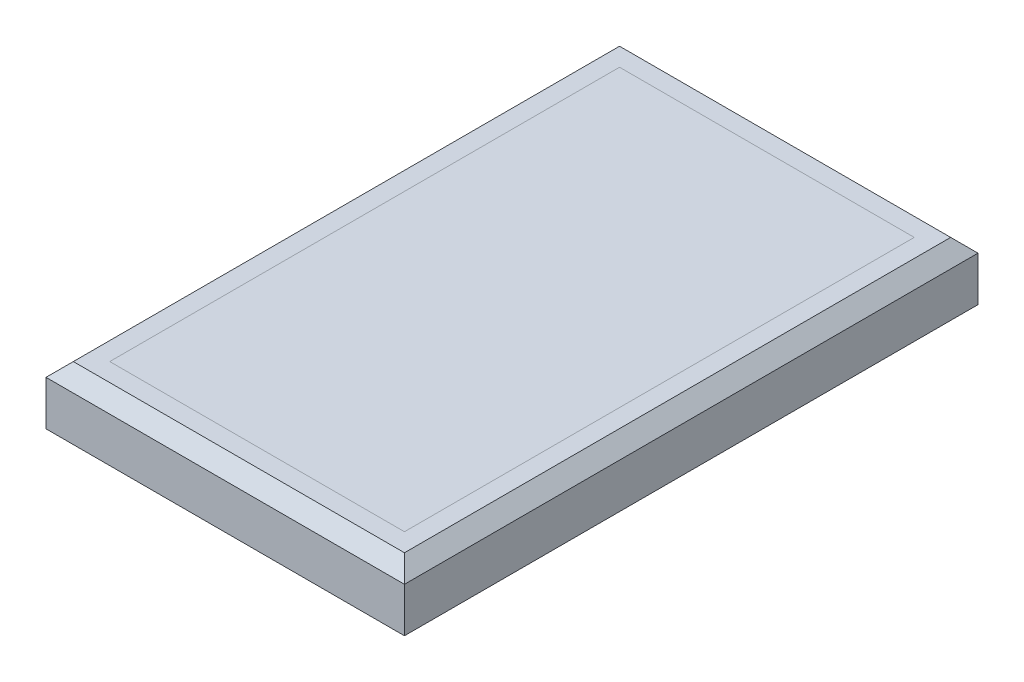
from build123d import *

# Parameters (mm, degrees)
SKETCH1_W           = 250.000000126
SKETCH1_H           = 400.0000001
BOSS_EXTRUDE1_DEPTH = 40.64
SKETCH2_W           = 205.550000126
SKETCH2_H           = 355.5500001
CUT_EXTRUDE1_DEPTH  = 38.1
CHAMFER1_SIZE       = 9.525
SKETCH3_W           = 205.550000126
SKETCH3_H           = 355.5500001
BOSS_EXTRUDE2_DEPTH = 3.175
SKETCH4_W           = 3.175
SKETCH4_H           = 355.5500001
CUT_EXTRUDE2_DEPTH  = 7.62
SKETCH5_W           = 205.550000126
SKETCH5_H           = 3.175
CUT_EXTRUDE3_DEPTH  = 7.62
SKETCH6_W           = 31.612500021
SKETCH6_H           = 32.69750001
BOSS_EXTRUDE3_DEPTH = 3.175
SKETCH7_W           = 199.200000126
SKETCH7_H           = 349.2000001
CUT_EXTRUDE4_DEPTH  = 7.62
SKETCH9_W           = 205.550000126
SKETCH9_H           = 355.5500001
BOSS_EXTRUDE5_DEPTH = 3.175
SKETCH10_W          = 199.200000126
SKETCH10_H          = 349.2000001
BOSS_EXTRUDE6_DEPTH = 3.175


with BuildPart() as part:
    # Sketch1 → Boss-Extrude1 (new body)
    with BuildSketch(Plane(origin=(0, 0, 0), x_dir=(1, 0, 0), z_dir=(0, 1, 0))):
        Rectangle(SKETCH1_W, SKETCH1_H)
    extrude(amount=BOSS_EXTRUDE1_DEPTH)

    # Sketch2 → Cut-Extrude1 (cut)
    with BuildSketch(Plane(origin=(0, 40.64, 0), x_dir=(1, 0, 0), z_dir=(0, 1, 0))):
        Rectangle(SKETCH2_W, SKETCH2_H)
    extrude(amount=-CUT_EXTRUDE1_DEPTH, mode=Mode.SUBTRACT)

    # Chamfer1
    chamfer1_edges = [part.edges().sort_by_distance(p)[0] for p in [
        (125.000000063, 40.64, 0),
        (0, 40.64, -200.00000005),
        (-125.000000063, 40.64, 0),
        (0, 40.64, 200.00000005),
    ]]
    chamfer(chamfer1_edges, length=CHAMFER1_SIZE)

    # Sketch7 → Cut-Extrude4 (cut)
    with BuildSketch(Plane.XZ):
        Rectangle(SKETCH7_W, SKETCH7_H)
    extrude(amount=-CUT_EXTRUDE4_DEPTH, mode=Mode.SUBTRACT)


with BuildPart() as body_2:
    # Sketch3 → Boss-Extrude2 (new body)
    with BuildSketch(Plane(origin=(0, 37.465, 0), x_dir=(1, 0, 0), z_dir=(0, 1, 0))):
        Rectangle(SKETCH3_W, SKETCH3_H)
    extrude(amount=-BOSS_EXTRUDE2_DEPTH)

    # Sketch4 → Cut-Extrude2 (cut)
    with BuildSketch(Plane(origin=(0, 37.465, 0), x_dir=(1, 0, 0), z_dir=(0, 1, 0))):
        Rectangle(SKETCH4_W, SKETCH4_H)
        with Locations((69.575000042, 0)):
            Rectangle(SKETCH4_W, SKETCH4_H)
        with Locations((-69.575000042, 0)):
            Rectangle(SKETCH4_W, SKETCH4_H)
        with Locations((34.787500021, 0)):
            Rectangle(SKETCH4_W, SKETCH4_H)
        with Locations((-34.787500021, 0)):
            Rectangle(SKETCH4_W, SKETCH4_H)
    extrude(amount=-CUT_EXTRUDE2_DEPTH, mode=Mode.SUBTRACT)

    # Sketch5 → Cut-Extrude3 (cut)
    with BuildSketch(Plane(origin=(0, 37.465, 0), x_dir=(1, 0, 0), z_dir=(0, 1, 0))):
        Rectangle(SKETCH5_W, SKETCH5_H)
        with Locations((0, -35.87250001)):
            Rectangle(SKETCH5_W, SKETCH5_H)
        with Locations((0, -71.74500002)):
            Rectangle(SKETCH5_W, SKETCH5_H)
        with Locations((0, -107.61750003)):
            Rectangle(SKETCH5_W, SKETCH5_H)
        with Locations((0, -143.49000004)):
            Rectangle(SKETCH5_W, SKETCH5_H)
        with Locations((0, 35.87250001)):
            Rectangle(SKETCH5_W, SKETCH5_H)
        with Locations((0, 71.74500002)):
            Rectangle(SKETCH5_W, SKETCH5_H)
        with Locations((0, 107.61750003)):
            Rectangle(SKETCH5_W, SKETCH5_H)
        with Locations((0, 143.49000004)):
            Rectangle(SKETCH5_W, SKETCH5_H)
    extrude(amount=-CUT_EXTRUDE3_DEPTH, mode=Mode.SUBTRACT)


with BuildPart() as body_3:
    # Sketch6 → Boss-Extrude3 (new body)
    with BuildSketch(Plane(origin=(0, 37.465, 0), x_dir=(1, 0, 0), z_dir=(0, 1, 0))):
        Polygon((-102.775000063, -141.90250004), (-102.775000063, -145.07750004), (-71.162500042, -145.07750004), (-71.162500042, -177.77500005), (-67.987500042, -177.77500005), (-67.987500042, -145.07750004), (-36.375000021, -145.07750004), (-36.375000021, -177.77500005), (-33.200000021, -177.77500005), (-33.200000021, -145.07750004), (-1.5875, -145.07750004), (-1.5875, -177.77500005), (1.5875, -177.77500005), (1.5875, -145.07750004), (33.200000021, -145.07750004), (33.200000021, -177.77500005), (36.375000021, -177.77500005), (36.375000021, -145.07750004), (67.987500042, -145.07750004), (67.987500042, -177.77500005), (71.162500042, -177.77500005), (71.162500042, -145.07750004), (102.775000063, -145.07750004), (102.775000063, -141.90250004), (71.162500042, -141.90250004), (71.162500042, -109.20500003), (102.775000063, -109.20500003), (102.775000063, -106.03000003), (71.162500042, -106.03000003), (71.162500042, -73.33250002), (102.775000063, -73.33250002), (102.775000063, -70.15750002), (71.162500042, -70.15750002), (71.162500042, -37.46000001), (102.775000063, -37.46000001), (102.775000063, -34.28500001), (71.162500042, -34.28500001), (71.162500042, -1.5875), (102.775000063, -1.5875), (102.775000063, 1.5875), (71.162500042, 1.5875), (71.162500042, 34.28500001), (102.775000063, 34.28500001), (102.775000063, 37.46000001), (71.162500042, 37.46000001), (71.162500042, 70.15750002), (102.775000063, 70.15750002), (102.775000063, 73.33250002), (71.162500042, 73.33250002), (71.162500042, 106.03000003), (102.775000063, 106.03000003), (102.775000063, 109.20500003), (71.162500042, 109.20500003), (71.162500042, 141.90250004), (102.775000063, 141.90250004), (102.775000063, 145.07750004), (71.162500042, 145.07750004), (71.162500042, 177.77500005), (67.987500042, 177.77500005), (67.987500042, 145.07750004), (36.375000021, 145.07750004), (36.375000021, 177.77500005), (33.200000021, 177.77500005), (33.200000021, 145.07750004), (1.5875, 145.07750004), (1.5875, 177.77500005), (-1.5875, 177.77500005), (-1.5875, 145.07750004), (-33.200000021, 145.07750004), (-33.200000021, 177.77500005), (-36.375000021, 177.77500005), (-36.375000021, 145.07750004), (-67.987500042, 145.07750004), (-67.987500042, 177.77500005), (-71.162500042, 177.77500005), (-71.162500042, 145.07750004), (-102.775000063, 145.07750004), (-102.775000063, 141.90250004), (-71.162500042, 141.90250004), (-71.162500042, 109.20500003), (-102.775000063, 109.20500003), (-102.775000063, 106.03000003), (-71.162500042, 106.03000003), (-71.162500042, 73.33250002), (-102.775000063, 73.33250002), (-102.775000063, 70.15750002), (-71.162500042, 70.15750002), (-71.162500042, 37.46000001), (-102.775000063, 37.46000001), (-102.775000063, 34.28500001), (-71.162500042, 34.28500001), (-71.162500042, 1.5875), (-102.775000063, 1.5875), (-102.775000063, -1.5875), (-71.162500042, -1.5875), (-71.162500042, -34.28500001), (-102.775000063, -34.28500001), (-102.775000063, -37.46000001), (-71.162500042, -37.46000001), (-71.162500042, -70.15750002), (-102.775000063, -70.15750002), (-102.775000063, -73.33250002), (-71.162500042, -73.33250002), (-71.162500042, -106.03000003), (-102.775000063, -106.03000003), (-102.775000063, -109.20500003), (-71.162500042, -109.20500003), (-71.162500042, -141.90250004), align=None)
        with Locations((-52.181250032, -125.553750035)):
            Rectangle(SKETCH6_W, SKETCH6_H, mode=Mode.SUBTRACT)
        with Locations((-17.39375001, -125.553750035)):
            Rectangle(SKETCH6_W, SKETCH6_H, mode=Mode.SUBTRACT)
        with Locations((17.39375001, -125.553750035)):
            Rectangle(SKETCH6_W, SKETCH6_H, mode=Mode.SUBTRACT)
        with Locations((52.181250032, -125.553750035)):
            Rectangle(SKETCH6_W, SKETCH6_H, mode=Mode.SUBTRACT)
        with Locations((52.181250032, -89.681250025)):
            Rectangle(SKETCH6_W, SKETCH6_H, mode=Mode.SUBTRACT)
        with Locations((17.39375001, -89.681250025)):
            Rectangle(SKETCH6_W, SKETCH6_H, mode=Mode.SUBTRACT)
        with Locations((-17.39375001, -89.681250025)):
            Rectangle(SKETCH6_W, SKETCH6_H, mode=Mode.SUBTRACT)
        with Locations((-52.181250032, -89.681250025)):
            Rectangle(SKETCH6_W, SKETCH6_H, mode=Mode.SUBTRACT)
        with Locations((-52.181250032, -53.808750015)):
            Rectangle(SKETCH6_W, SKETCH6_H, mode=Mode.SUBTRACT)
        with Locations((-17.39375001, -53.808750015)):
            Rectangle(SKETCH6_W, SKETCH6_H, mode=Mode.SUBTRACT)
        with Locations((17.39375001, -53.808750015)):
            Rectangle(SKETCH6_W, SKETCH6_H, mode=Mode.SUBTRACT)
        with Locations((52.181250032, -53.808750015)):
            Rectangle(SKETCH6_W, SKETCH6_H, mode=Mode.SUBTRACT)
        with Locations((52.181250032, -17.936250005)):
            Rectangle(SKETCH6_W, SKETCH6_H, mode=Mode.SUBTRACT)
        with Locations((17.39375001, -17.936250005)):
            Rectangle(SKETCH6_W, SKETCH6_H, mode=Mode.SUBTRACT)
        with Locations((-17.39375001, -17.936250005)):
            Rectangle(SKETCH6_W, SKETCH6_H, mode=Mode.SUBTRACT)
        with Locations((-52.181250032, -17.936250005)):
            Rectangle(SKETCH6_W, SKETCH6_H, mode=Mode.SUBTRACT)
        with Locations((-52.181250032, 17.936250005)):
            Rectangle(SKETCH6_W, SKETCH6_H, mode=Mode.SUBTRACT)
        with Locations((-17.39375001, 17.936250005)):
            Rectangle(SKETCH6_W, SKETCH6_H, mode=Mode.SUBTRACT)
        with Locations((17.39375001, 17.936250005)):
            Rectangle(SKETCH6_W, SKETCH6_H, mode=Mode.SUBTRACT)
        with Locations((52.181250032, 17.936250005)):
            Rectangle(SKETCH6_W, SKETCH6_H, mode=Mode.SUBTRACT)
        with Locations((52.181250032, 125.553750035)):
            Rectangle(SKETCH6_W, SKETCH6_H, mode=Mode.SUBTRACT)
        with Locations((52.181250032, 89.681250025)):
            Rectangle(SKETCH6_W, SKETCH6_H, mode=Mode.SUBTRACT)
        with Locations((52.181250032, 53.808750015)):
            Rectangle(SKETCH6_W, SKETCH6_H, mode=Mode.SUBTRACT)
        with Locations((17.39375001, 53.808750015)):
            Rectangle(SKETCH6_W, SKETCH6_H, mode=Mode.SUBTRACT)
        with Locations((17.39375001, 89.681250025)):
            Rectangle(SKETCH6_W, SKETCH6_H, mode=Mode.SUBTRACT)
        with Locations((17.39375001, 125.553750035)):
            Rectangle(SKETCH6_W, SKETCH6_H, mode=Mode.SUBTRACT)
        with Locations((-17.39375001, 125.553750035)):
            Rectangle(SKETCH6_W, SKETCH6_H, mode=Mode.SUBTRACT)
        with Locations((-17.39375001, 89.681250025)):
            Rectangle(SKETCH6_W, SKETCH6_H, mode=Mode.SUBTRACT)
        with Locations((-17.39375001, 53.808750015)):
            Rectangle(SKETCH6_W, SKETCH6_H, mode=Mode.SUBTRACT)
        with Locations((-52.181250032, 53.808750015)):
            Rectangle(SKETCH6_W, SKETCH6_H, mode=Mode.SUBTRACT)
        with Locations((-52.181250032, 125.553750035)):
            Rectangle(SKETCH6_W, SKETCH6_H, mode=Mode.SUBTRACT)
        with Locations((-52.181250032, 89.681250025)):
            Rectangle(SKETCH6_W, SKETCH6_H, mode=Mode.SUBTRACT)
    extrude(amount=-BOSS_EXTRUDE3_DEPTH)


with BuildPart() as body_4:
    # Sketch9 → Boss-Extrude5 (new body)
    with BuildSketch(Plane(origin=(0, 40.64, 0), x_dir=(1, 0, 0), z_dir=(0, 1, 0))):
        Rectangle(SKETCH9_W, SKETCH9_H)
    extrude(amount=-BOSS_EXTRUDE5_DEPTH)


with BuildPart() as body_5:
    # Sketch10 → Boss-Extrude6 (new body)
    with BuildSketch(Plane.XZ):
        Rectangle(SKETCH10_W, SKETCH10_H)
    extrude(amount=-BOSS_EXTRUDE6_DEPTH)


solid = Compound([part.part, body_2.part, body_3.part, body_4.part, body_5.part])
